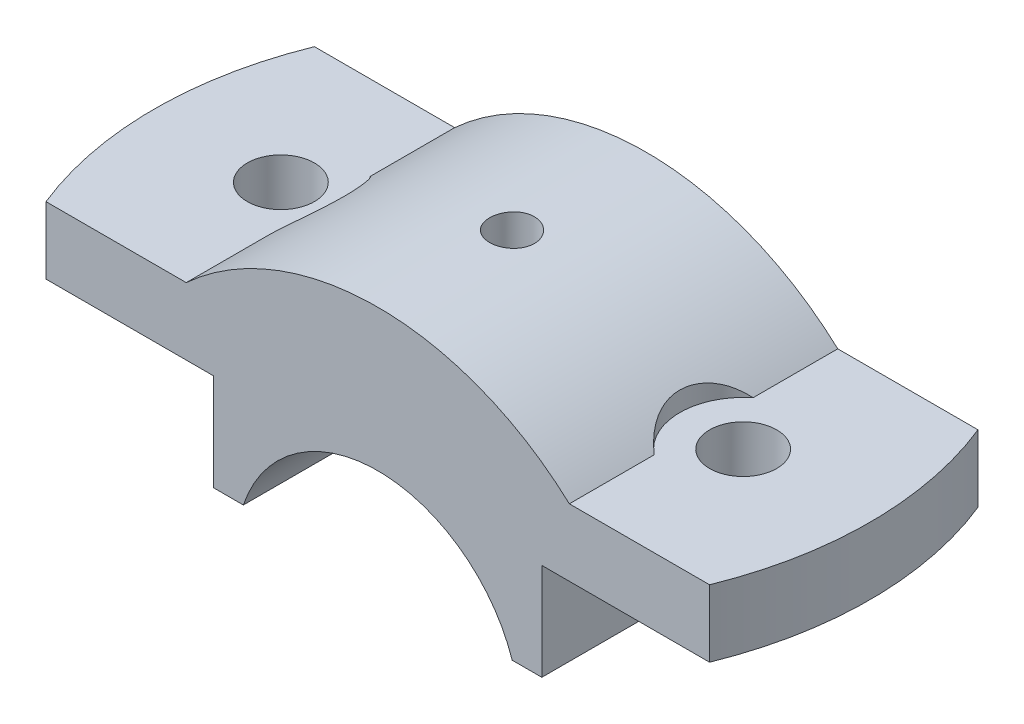
from build123d import *

# Parameters (mm, degrees)
BOSS_EXTRUDE1_DEPTH                     = 18
CUT_EXTRUDE3_DEPTH                      = 36
SKETCH3_R                               = 4.5
CUT_EXTRUDE4_DEPTH                      = 23
CUT_EXTRUDE5_DEPTH                      = 11
CBORE_FOR_M5_HEX_HEAD_BOLT1_D           = 5
CBORE_FOR_M5_HEX_HEAD_BOLT1_CBORE_D     = 6
CBORE_FOR_M5_HEX_HEAD_BOLT1_CBORE_DEPTH = 13


with BuildPart() as part:
    # Sketch1 → Boss-Extrude1 (new body, symmetric)
    with BuildSketch(Plane.XY):
        with BuildLine():
            Line((18.027756377, 6), (22, 6))
            Line((22, 6), (22, 19))
            Line((22, 19), (50, 19))
            Line((50, 19), (50, 28))
            Line((50, 28), (25.690465157, 28))
            ThreePointArc((25.690465157, 28), (0, 38), (-25.690465157, 28))
            Line((-25.690465157, 28), (-50, 28))
            Line((-50, 28), (-50, 19))
            Line((-50, 19), (-22, 19))
            Line((-22, 19), (-22, 6))
            Line((-22, 6), (-18.027756377, 6))
            ThreePointArc((-18.027756377, 6), (0, 19), (18.027756377, 6))
        make_face()
    extrude(amount=BOSS_EXTRUDE1_DEPTH, both=True)

    # Sketch2 → Cut-Extrude3 (cut)
    with BuildSketch(Plane(origin=(0, 28, 0), x_dir=(1, 0, 0), z_dir=(0, 1, 0))):
        with BuildLine():
            Line((-50, -18), (-44.497190923, -18))
            ThreePointArc((-44.497190923, -18), (-48, 0), (-44.497190923, 18))
            Line((-44.497190923, 18), (-50, 18))
            Line((-50, 18), (-50, -18))
        make_face()
    cut_extrude3 = extrude(amount=-CUT_EXTRUDE3_DEPTH, mode=Mode.SUBTRACT)

    # Sketch3 → Cut-Extrude4 (cut, through all)
    with BuildSketch(Plane(origin=(0, 28, 0), x_dir=(1, 0, 0), z_dir=(0, 1, 0))):
        with Locations(Location((-31, 0, 0), (0, 0, 180))):  # turned: the seam where the file's is
            Circle(SKETCH3_R)
    cut_extrude4 = extrude(amount=-CUT_EXTRUDE4_DEPTH, mode=Mode.SUBTRACT)

    # Mirror2: Cut-Extrude3, Cut-Extrude4 across plane
    add(cut_extrude3.mirror(Plane(origin=(0, 0, 0), x_dir=(0, 0, 1), z_dir=(1, 0, 0))), mode=Mode.SUBTRACT)
    add(cut_extrude4.mirror(Plane(origin=(0, 0, 0), x_dir=(0, 0, 1), z_dir=(1, 0, 0))), mode=Mode.SUBTRACT)

    # Sketch4 → Cut-Extrude5 (cut, through all)
    with BuildSketch(Plane(origin=(0, 28, 0), x_dir=(1, 0, 0), z_dir=(0, 1, 0))):
        with BuildLine():
            Line((-25.690465157, -6.637683312), (-25.690465157, 6.637683312))
            ThreePointArc((-25.690465157, 6.637683312), (-22.5, 0), (-25.690465157, -6.637683312))
        make_face()
    cut_extrude5 = extrude(amount=CUT_EXTRUDE5_DEPTH, mode=Mode.SUBTRACT)

    # Mirror15: Cut-Extrude5 across plane
    add(cut_extrude5.mirror(Plane(origin=(0, 0, 0), x_dir=(0, 0, 1), z_dir=(1, 0, 0))), mode=Mode.SUBTRACT)

    # CBORE for M5 Hex Head Bolt1 (through all)
    with Locations(Plane(origin=(0, 38, 0), x_dir=(1, 0, 0), z_dir=(0, 1, 0))):
        with Locations((0, 0)):
            CounterBoreHole(CBORE_FOR_M5_HEX_HEAD_BOLT1_D / 2, CBORE_FOR_M5_HEX_HEAD_BOLT1_CBORE_D / 2, CBORE_FOR_M5_HEX_HEAD_BOLT1_CBORE_DEPTH)


solid = part.part
